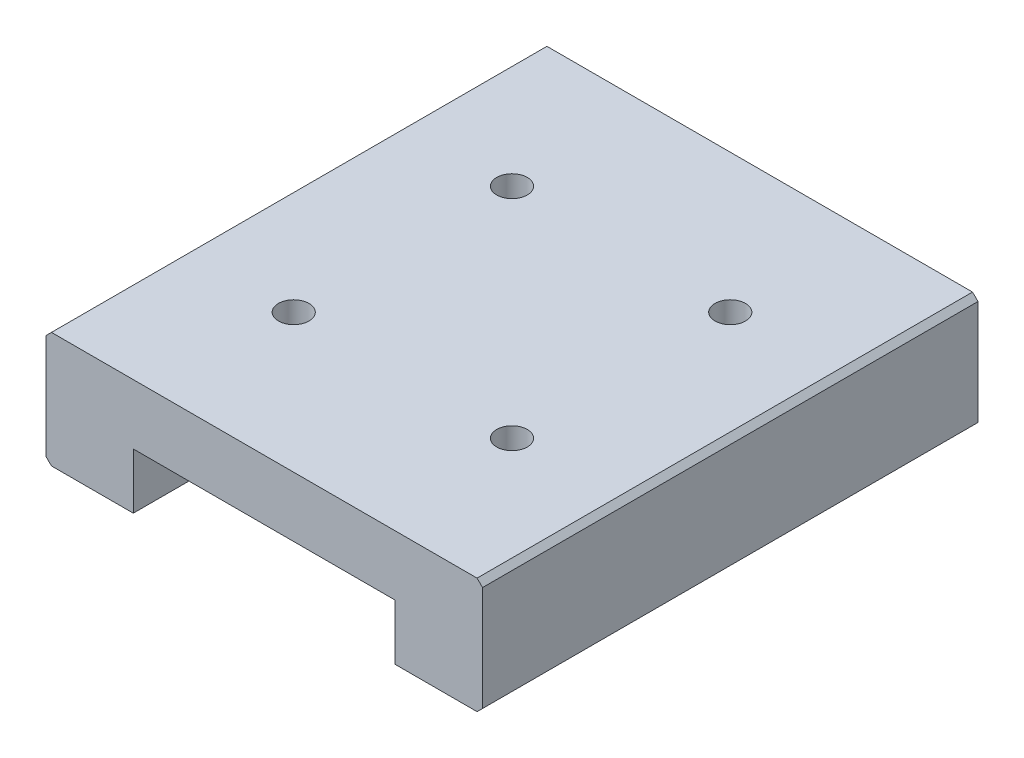
from build123d import *

# Parameters (mm, degrees)
EXTRUDE_1_DEPTH     = 45.4
HOLE_WIZARD_1_D     = 2.8
HOLE_WIZARD_1_DEPTH = 3.5


with BuildPart() as part:
    # 草图1 → 凸台-拉伸1 (new body)
    with BuildSketch(Plane.XY):
        Polygon((-25.32278481, 7.405063291), (13.67721519, 7.405063291), (14.17721519, 6.905063291), (14.17721519, -2.694936709), (13.67721519, -3.194936709), (6.17721519, -3.194936709), (6.17721519, 1.905063291), (-17.82278481, 1.905063291), (-17.82278481, -3.194936709), (-25.32278481, -3.194936709), (-25.82278481, -2.694936709), (-25.82278481, 6.905063291), align=None)
    extrude(amount=EXTRUDE_1_DEPTH)

    # 孔1
    with Locations(Plane(origin=(4.17721519, 7.405063291, 12.7), x_dir=(0, 0, 1), z_dir=(0, 1, 0))):
        with Locations((0, 0), (20, 0), (0, -20), (20, -20)):
            Hole(HOLE_WIZARD_1_D / 2, depth=HOLE_WIZARD_1_DEPTH)


solid = part.part
